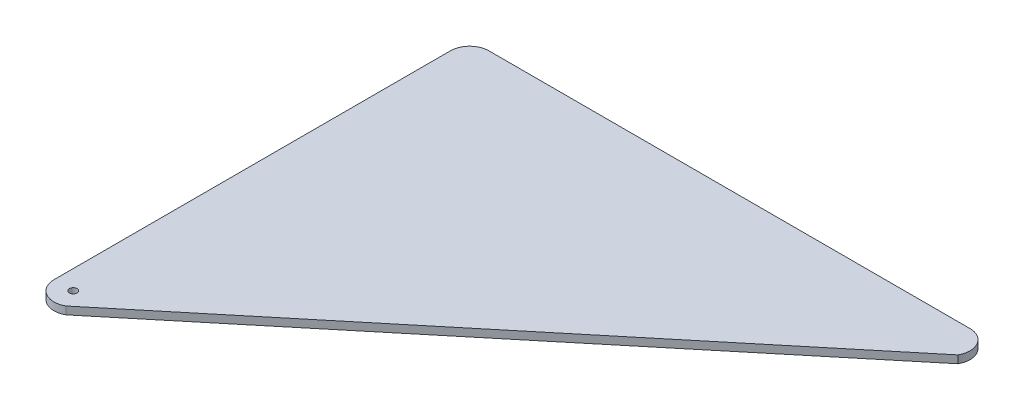
from build123d import *

# Parameters (mm, degrees)
ESQUISSE1_R        = 1
BOSS_EXTRU_2_DEPTH = 2


with BuildPart() as part:
    # Esquisse1 → Boss.-Extru.2 (new body)
    with BuildSketch(Plane(origin=(0, 0, 0), x_dir=(1, 0, 0), z_dir=(0, 1, 0))):
        with BuildLine():
            Line((129.333821146, 100.5), (2.5, -4.330127019))
            ThreePointArc((2.5, -4.330127019), (-2.5, -4.330127019), (-5, 0))
            Line((-5, 0), (-5, 103))
            ThreePointArc((-5, 103), (-3.535533906, 106.535533906), (0, 108))
            Line((0, 108), (125.003694127, 108))
            ThreePointArc((125.003694127, 108), (129.333821146, 105.5), (129.333821146, 100.5))
        make_face()
        Circle(ESQUISSE1_R, mode=Mode.SUBTRACT)
    extrude(amount=BOSS_EXTRU_2_DEPTH)


solid = part.part
